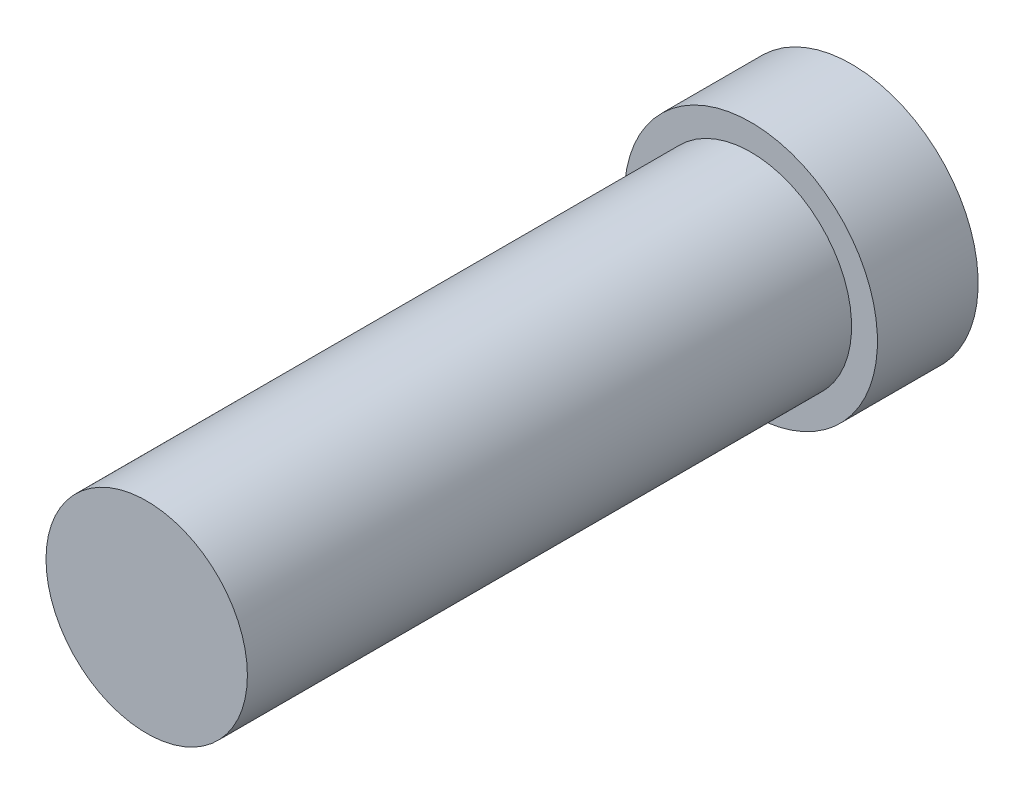
from build123d import *

# Parameters (mm, degrees)
SKETCH1_R                = 3
BOSS_EXTRUDE1_DEPTH      = 20
SKETCH2_R                = 3.770107986
SKETCH2_R_2              = 2.770107986
EXTRUDE_THIN1_DEPTH      = 1
EXTRUDE_THIN1_DEPTH_BACK = 2


with BuildPart() as part:
    # Sketch1 → Boss-Extrude1 (new body)
    with BuildSketch(Plane.XY):
        Circle(SKETCH1_R)
    extrude(amount=BOSS_EXTRUDE1_DEPTH)

    # Sketch2 → Extrude-Thin1 (add, two sides)
    with BuildSketch(Plane(origin=(0, 0, 0), x_dir=(-1, 0, 0), z_dir=(0, 0, -1))) as extrude_thin1_sk:
        Circle(SKETCH2_R)
        Circle(SKETCH2_R_2, mode=Mode.SUBTRACT)
    extrude(amount=EXTRUDE_THIN1_DEPTH)
    extrude(extrude_thin1_sk.sketch, amount=-EXTRUDE_THIN1_DEPTH_BACK)


solid = part.part
